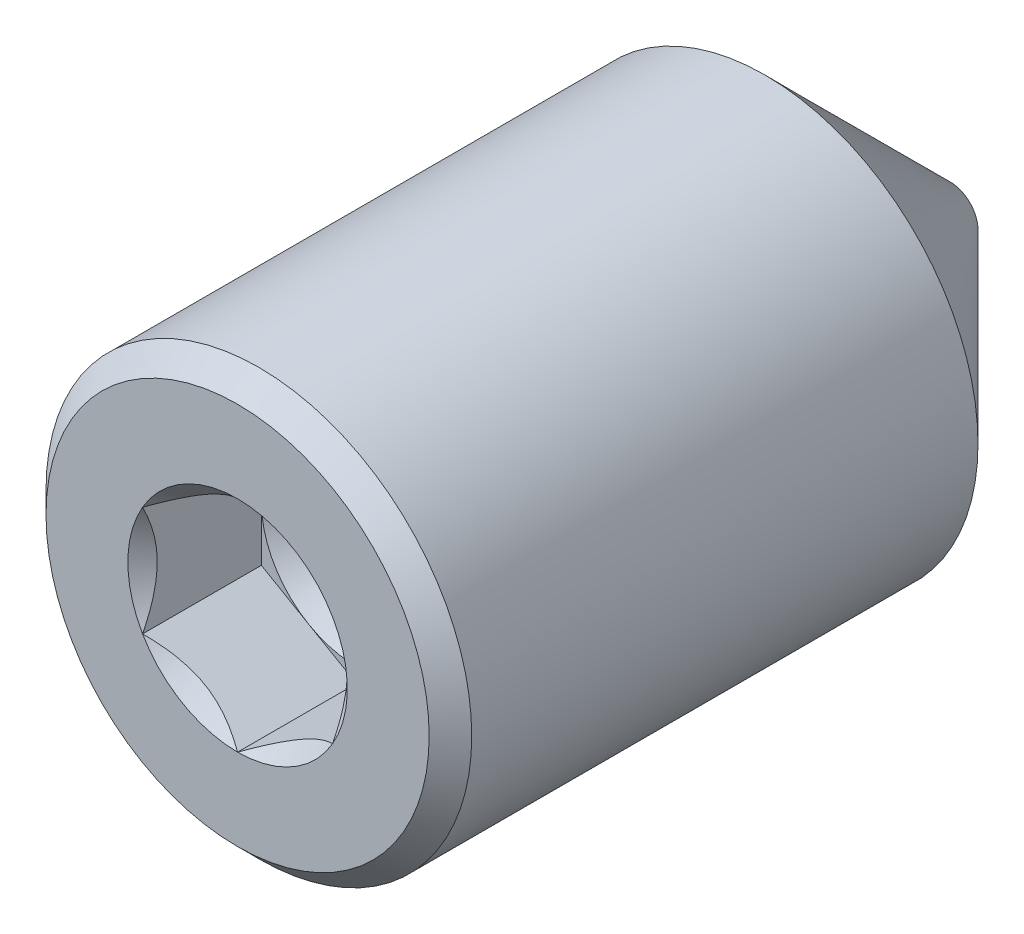
from build123d import *

# Parameters (mm, degrees)
CHAMFER1_SIZE      = 0.14224
CUT_EXTRUDE1_DEPTH = 0.79375


with BuildPart() as part:
    # Sketch2 → Revolve1 (revolve)
    with BuildSketch(Plane(origin=(0, 0, 0), x_dir=(0, 0, -1), z_dir=(1, 0, 0))):
        Polygon((-2.38125, 0), (2.38125, 0), (2.38125, 0.184912), (1.143762, 1.4224), (-2.38125, 1.4224), align=None)
    revolve(axis=Axis((0, 0, 2.38125), (0, 0, -1)))

    # Chamfer1
    chamfer1_edges = [part.edges().sort_by_distance(p)[0] for p in [
        (0, -1.4224, 2.38125),
    ]]
    chamfer(chamfer1_edges, length=CHAMFER1_SIZE)

    # Sketch3 → Cut-Extrude1 (cut)
    with BuildSketch(Plane.XY.offset(2.38125)):
        Polygon((0, -0.733234842), (0.635, -0.366617421), (0.635, 0.366617421), (0, 0.733234842), (-0.635, 0.366617421), (-0.635, -0.366617421), align=None)
    extrude(amount=-CUT_EXTRUDE1_DEPTH, mode=Mode.SUBTRACT)

    # Cut-Extrude2 cone 1 section (through the dimple's axis) → Cut-Extrude2 (revolve, cut)
    with BuildSketch(Plane(origin=(0, 0, 2.38125), x_dir=(0, -1, 0), z_dir=(1, 0, 0))):
        Polygon((0, 0), (0.733234842, 0), (0, 0.733234842), align=None)
    revolve(axis=Axis((0, 0, 2.38125), (0, 0, -1)), mode=Mode.SUBTRACT)

    # Cut-Extrude3 cone 1 section (through the dimple's axis) → Cut-Extrude3 (revolve, cut)
    with BuildSketch(Plane(origin=(0, 0, 1.5875), x_dir=(0, -1, 0), z_dir=(1, 0, 0))):
        Polygon((0, 0), (0.635, 0), (0, 0.635), align=None)
    revolve(axis=Axis((0, 0, 1.5875), (0, 0, -1)), mode=Mode.SUBTRACT)


solid = part.part
